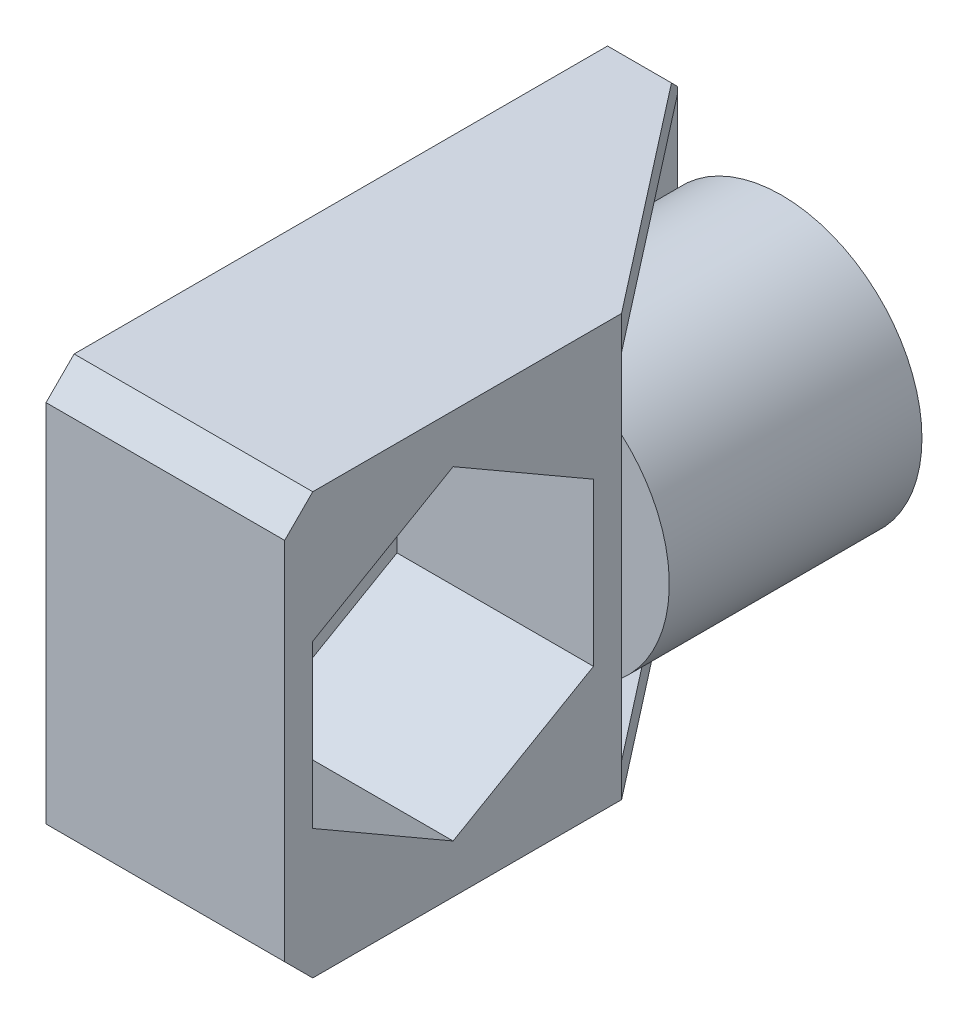
from build123d import *

# Parameters (mm, degrees)
SALIENTE_EXTRUIR1_DEPTH = 9
CROQUIS3_W              = 21
CROQUIS3_H              = 15
SALIENTE_EXTRUIR2_DEPTH = 1.5
CROQUIS4_R              = 3
CORTAR_EXTRUIR1_DEPTH   = 11.2
CROQUIS5_W              = 12
CROQUIS5_H              = 15
SALIENTE_EXTRUIR3_DEPTH = 7
CORTAR_EXTRUIR2_DEPTH   = 7
CHAFL_N1_SIZE           = 0.5
SALIENTE_EXTRUIR4_DEPTH = 1.2
CHAFL_N2_SIZE           = 1


with BuildPart() as part:
    # Croquis1 → Saliente-Extruir1 (new body)
    with BuildSketch(Plane.XY):
        with BuildLine():
            Line((-4.330127019, 2.5), (-5.2, 2.5))
            Line((-5.2, 2.5), (-5.2, -2.5))
            Line((-5.2, -2.5), (-4.330127019, -2.5))
            ThreePointArc((-4.330127019, -2.5), (-0.868240888, -4.924038765), (3.213938048, -3.830222216))
            ThreePointArc((3.213938048, -3.830222216), (5, 0), (3.213938048, 3.830222216))
            ThreePointArc((3.213938048, 3.830222216), (-0.868240888, 4.924038765), (-4.330127019, 2.5))
        make_face()
        with BuildLine():
            ThreePointArc((1.928362829, 2.298133329), (-3, 0), (1.928362829, -2.298133329))
            ThreePointArc((1.928362829, -2.298133329), (3, 0), (1.928362829, 2.298133329))
        make_face(mode=Mode.SUBTRACT)
    extrude(amount=SALIENTE_EXTRUIR1_DEPTH)

    # Croquis3 → Saliente-Extruir2 (add)
    with BuildSketch(Plane.ZY.offset(5.2)):
        with Locations((10.5, 0)):
            Rectangle(CROQUIS3_W, CROQUIS3_H)
    extrude(amount=-SALIENTE_EXTRUIR2_DEPTH)

    # Croquis4 → Cortar-Extruir1 (cut, through all)
    with BuildSketch(Plane.ZY.offset(5.2)):
        with Locations((15, 0)):
            Circle(CROQUIS4_R)
    extrude(amount=-CORTAR_EXTRUIR1_DEPTH, mode=Mode.SUBTRACT)

    # Croquis5 → Saliente-Extruir3 (add)
    with BuildSketch(Plane(origin=(-3.7, 0, 0), x_dir=(0, 0, -1), z_dir=(1, 0, 0))):
        with Locations((-15, 0)):
            Rectangle(CROQUIS5_W, CROQUIS5_H)
    extrude(amount=SALIENTE_EXTRUIR3_DEPTH)

    # Croquis7 → Cortar-Extruir2 (cut)
    with BuildSketch(Plane(origin=(3.3, 0, 0), x_dir=(0, 0, -1), z_dir=(1, 0, 0))):
        Polygon((-10, -2.886751346), (-10, 2.886751346), (-15, 5.773502692), (-20, 2.886751346), (-20, -2.886751346), (-15, -5.773502692), align=None)
    extrude(amount=-CORTAR_EXTRUIR2_DEPTH, mode=Mode.SUBTRACT)

    # Chaflán1
    chafl_n1_edges = [part.edges().sort_by_distance(p)[0] for p in [
        (-1.928362829, 2.298133329, 0),
    ]]
    chamfer(chafl_n1_edges, length=CHAFL_N1_SIZE)

    # Croquis8 → Saliente-Extruir4 (add)
    with BuildSketch(Plane(origin=(0, 7.5, 0), x_dir=(1, 0, 0), z_dir=(0, 1, 0))):
        Polygon((-3.7, 0), (3.3, -9), (-3.7, -9), align=None)
    saliente_extruir4 = extrude(amount=-SALIENTE_EXTRUIR4_DEPTH)

    # Simetría1: Saliente-Extruir4 across plane
    add(saliente_extruir4.mirror(Plane.ZX))

    # Chaflán2
    chafl_n2_edges = [part.edges().sort_by_distance(p)[0] for p in [
        (-4.45, -7.5, 0),
        (-4.45, 7.5, 0),
        (-0.95, 7.5, 21),
        (-0.95, -7.5, 21),
    ]]
    chamfer(chafl_n2_edges, length=CHAFL_N2_SIZE)


solid = part.part
